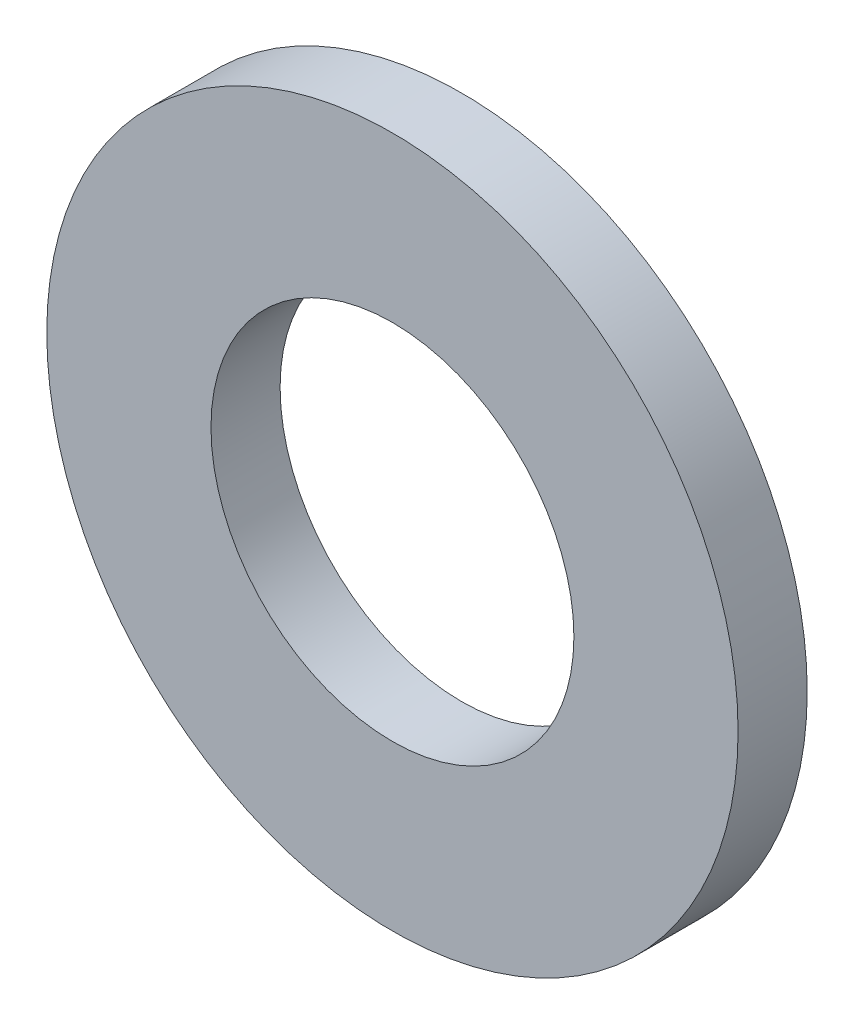
from build123d import *

# Parameters (mm, degrees)
SKETCH1_R          = 10
SKETCH1_R_2        = 5.25
BASE_EXTRUDE_DEPTH = 2


with BuildPart() as part:
    # Sketch1 → Base-Extrude (new body)
    with BuildSketch(Plane.XY):
        Circle(SKETCH1_R)
        Circle(SKETCH1_R_2, mode=Mode.SUBTRACT)
    extrude(amount=BASE_EXTRUDE_DEPTH)


solid = part.part
